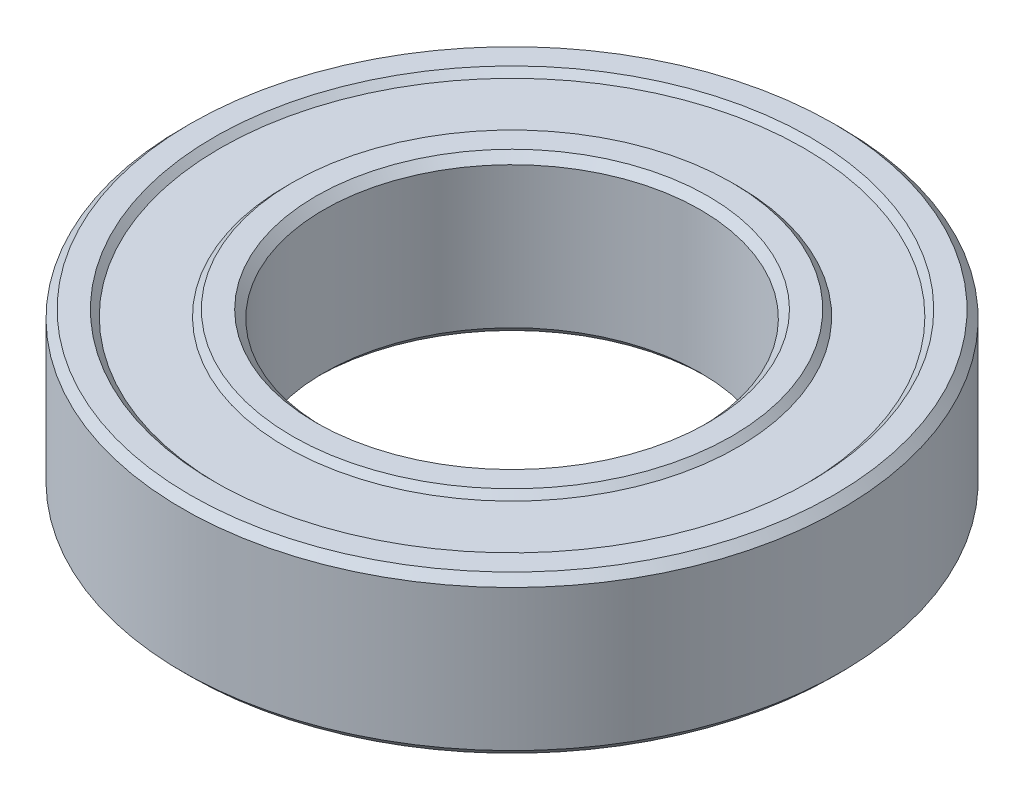
from build123d import *


with BuildPart() as part:
    # Sketch1 → Revolve1 (revolve)
    with BuildSketch(Plane.XY):
        Polygon((6, 2.25), (6, -2.25), (6.25, -2.5), (7, -2.5), (7.2, -2.3), (9.3, -2.3), (9.5, -2.5), (10.25, -2.5), (10.5, -2.25), (10.5, 2.25), (10.25, 2.5), (9.5, 2.5), (9.3, 2.3), (7.2, 2.3), (7, 2.5), (6.25, 2.5), align=None)
    revolve(axis=Axis((0, -1.349421972, 0), (0, 1, 0)))


solid = part.part
